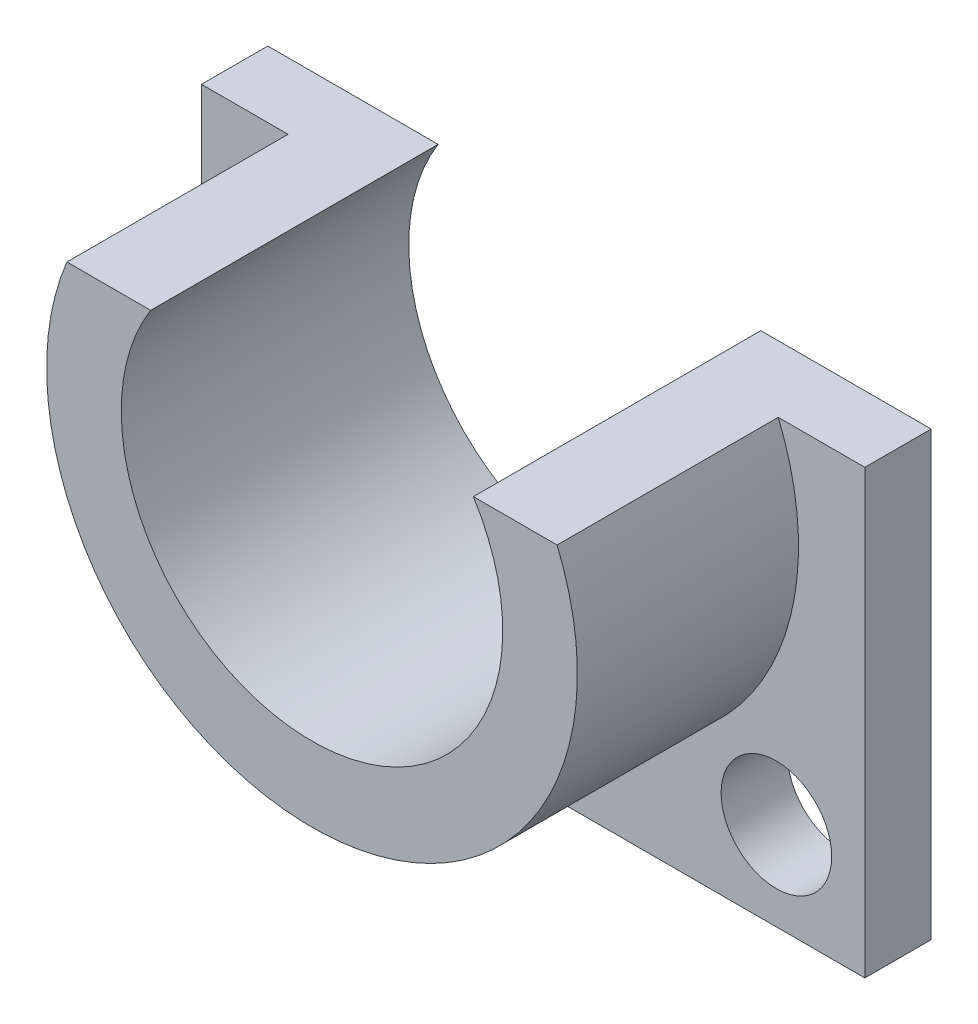
from build123d import *
from build123d.topology import SkipClean

# Parameters (mm, degrees)
BOSS_EXTRUDE1_DEPTH = 3.81
BOSS_EXTRUDE2_DEPTH = 12.7
SKETCH3_R           = 3.175
CUT_EXTRUDE1_DEPTH  = 3.81


with BuildPart() as part:
    # Sketch1 → Boss-Extrude1 (new body)
    with BuildSketch(Plane.XY):
        with BuildLine():
            Line((19.05, 57.15), (19.05, 31.75))
            Line((19.05, 31.75), (-19.05, 31.75))
            Line((-19.05, 31.75), (-19.05, 57.15))
            Line((-19.05, 57.15), (-9.265833749, 57.15))
            ThreePointArc((-9.265833749, 57.15), (0, 40.35425), (9.265833749, 57.15))
            Line((9.265833749, 57.15), (19.05, 57.15))
        make_face()
    extrude(amount=BOSS_EXTRUDE1_DEPTH)

    # Sketch2 → Boss-Extrude2 (add)
    with SkipClean():  # the faces are left unmerged after this step: merging them gives an invalid solid
        with BuildSketch(Plane.XY.offset(3.81)):
            with BuildLine():
                Line((14.075817419, 57.15), (9.265833749, 57.15))
                ThreePointArc((9.265833749, 57.15), (0, 40.35425), (-9.265833749, 57.15))
                Line((-9.265833749, 57.15), (-14.075817419, 57.15))
                ThreePointArc((-14.075817419, 57.15), (0, 36.068), (14.075817419, 57.15))
            make_face()
        extrude(amount=BOSS_EXTRUDE2_DEPTH)

    # Sketch3 → Cut-Extrude1 (cut)
    with SkipClean():  # the faces are left unmerged after this step: merging them gives an invalid solid
        with BuildSketch(Plane.XY.offset(3.81)):
            with Locations((-13.97, 36.83)):
                Circle(SKETCH3_R)
            with Locations((13.97, 36.83)):
                Circle(SKETCH3_R)
        extrude(amount=-CUT_EXTRUDE1_DEPTH, mode=Mode.SUBTRACT)


solid = part.part
